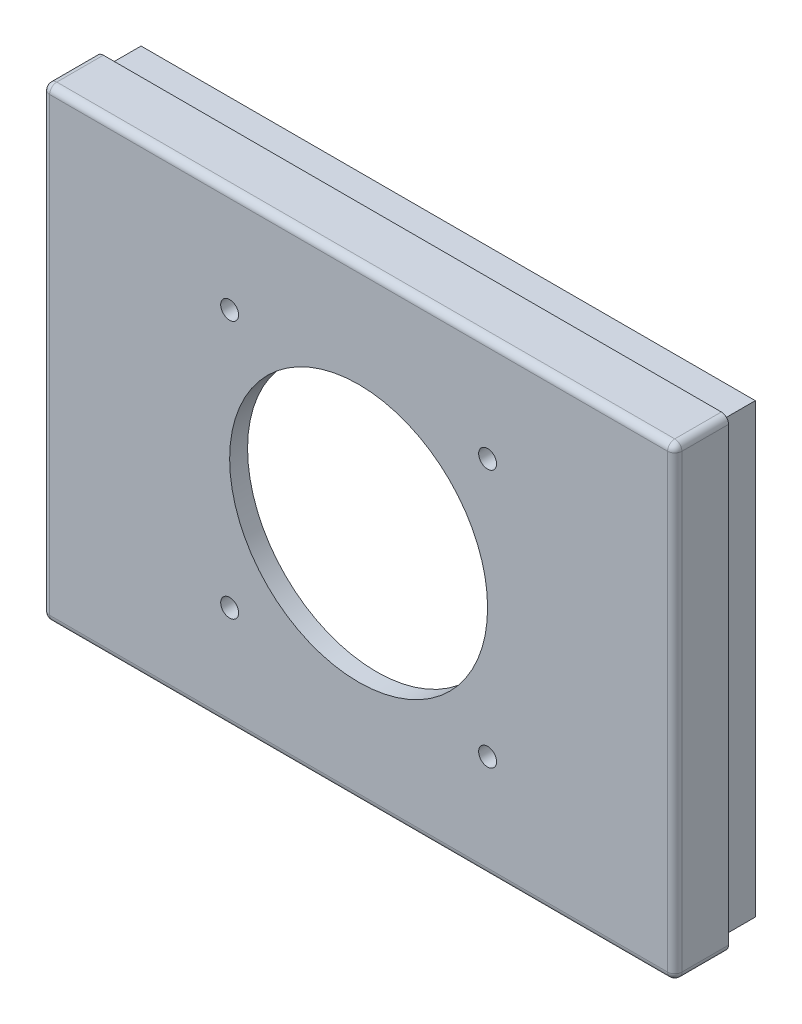
from build123d import *

# Parameters (mm, degrees)
SKETCH4_W           = 176.492
SKETCH4_H           = 129.883
BOSS_EXTRUDE1_DEPTH = 25
SKETCH5_OUTSIDE_W   = 222.602
SKETCH5_OUTSIDE_H   = 175.993
SKETCH5_OUTSIDE_W_2 = 176.492
SKETCH5_OUTSIDE_H_2 = 129.883
SKETCH5_OUTSIDE_W_3 = 166.492
SKETCH5_OUTSIDE_H_3 = 119.883
CUT_EXTRUDE1_DEPTH  = 20
SKETCH7_W           = 176.492
SKETCH7_H           = 129.883
SKETCH7_W_2         = 171.452
SKETCH7_H_2         = 124.843
CUT_EXTRUDE2_DEPTH  = 10
SKETCH12_R          = 36
CUT_EXTRUDE3_DEPTH  = 15
SKETCH13_R          = 2.5
CUT_EXTRUDE4_DEPTH  = 15
FILLET1_R           = 2


with BuildPart() as part:
    # Sketch4 → Boss-Extrude1 (new body)
    with BuildSketch(Plane.XY.offset(10)):
        with Locations((63.246, 39.9415)):
            Rectangle(SKETCH4_W, SKETCH4_H)
    extrude(amount=BOSS_EXTRUDE1_DEPTH)

    # Sketch5 outside → Cut-Extrude1 (cut)
    with BuildSketch(Plane(origin=(0, 0, 10), x_dir=(-1, 0, 0), z_dir=(0, 0, -1))):
        with Locations((-63.246, 39.9415)):
            Rectangle(SKETCH5_OUTSIDE_W, SKETCH5_OUTSIDE_H)
        with Locations((-63.246, 39.9415)):
            Rectangle(SKETCH5_OUTSIDE_W_2, SKETCH5_OUTSIDE_H_2, mode=Mode.SUBTRACT)
        with Locations((-63.246, 39.9415)):
            Rectangle(SKETCH5_OUTSIDE_W_3, SKETCH5_OUTSIDE_H_3)
    extrude(amount=-CUT_EXTRUDE1_DEPTH, mode=Mode.SUBTRACT)

    # Sketch7 → Cut-Extrude2 (cut)
    with BuildSketch(Plane(origin=(0, 0, 10), x_dir=(-1, 0, 0), z_dir=(0, 0, -1))):
        with Locations((-63.246, 39.9415)):
            Rectangle(SKETCH7_W, SKETCH7_H)
        with Locations((-63.246, 39.9415)):
            Rectangle(SKETCH7_W_2, SKETCH7_H_2, mode=Mode.SUBTRACT)
    extrude(amount=-CUT_EXTRUDE2_DEPTH, mode=Mode.SUBTRACT)

    # Sketch12 → Cut-Extrude3 (cut)
    with BuildSketch(Plane.XY.offset(35)):
        with Locations((63.246, 39.9415)):
            Circle(SKETCH12_R)
    extrude(amount=-CUT_EXTRUDE3_DEPTH, mode=Mode.SUBTRACT)

    # Sketch13 → Cut-Extrude4 (cut)
    with BuildSketch(Plane.XY.offset(35)):
        with Locations((27.246, 75.9415)):
            Circle(SKETCH13_R)
        with Locations((99.246, 75.9415)):
            Circle(SKETCH13_R)
        with Locations((99.246, 3.9415)):
            Circle(SKETCH13_R)
        with Locations((27.246, 3.9415)):
            Circle(SKETCH13_R)
    extrude(amount=-CUT_EXTRUDE4_DEPTH, mode=Mode.SUBTRACT)

    # Fillet1
    fillet1_edges = [part.edges().sort_by_distance(p)[0] for p in [
        (151.492, 39.9415, 35),
        (63.246, 104.883, 35),
        (-25, 39.9415, 35),
        (-25, 104.883, 27.5),
        (151.492, 104.883, 27.5),
        (151.492, -25, 27.5),
        (-25, -25, 27.5),
        (63.246, -25, 35),
    ]]
    fillet(fillet1_edges, radius=FILLET1_R)


solid = part.part
